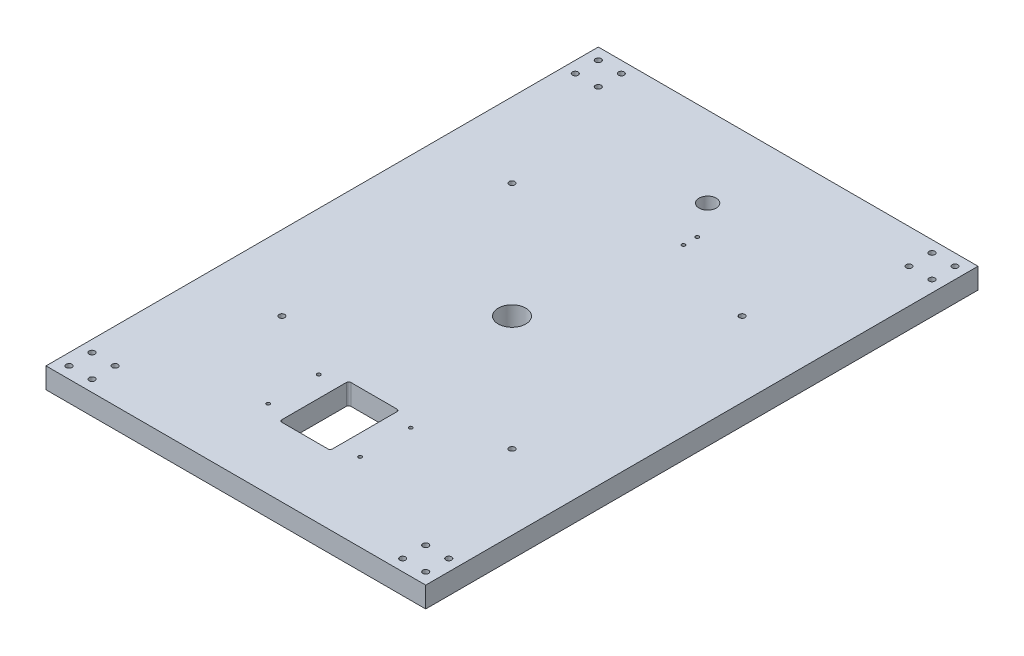
from build123d import *

# Parameters (mm, degrees)
SKETCH1_W           = 330
SKETCH1_H           = 480
SKETCH1_R           = 2.5
SKETCH1_R_2         = 12
SKETCH1_R_3         = 1.5
SKETCH1_R_4         = 7.5
BOSS_EXTRUDE1_DEPTH = 18


with BuildPart() as part:
    # Sketch1 → Boss-Extrude1 (new body)
    with BuildSketch(Plane(origin=(0, 0, 0), x_dir=(1, 0, 0), z_dir=(0, 1, 0))):
        with Locations((165, 240)):
            Rectangle(SKETCH1_W, SKETCH1_H)
        with Locations((10, 10)):
            Circle(SKETCH1_R, mode=Mode.SUBTRACT)
        with Locations((30, 10)):
            Circle(SKETCH1_R, mode=Mode.SUBTRACT)
        with Locations((10, 30)):
            Circle(SKETCH1_R, mode=Mode.SUBTRACT)
        with Locations((30, 30)):
            Circle(SKETCH1_R, mode=Mode.SUBTRACT)
        with Locations((320, 30)):
            Circle(SKETCH1_R, mode=Mode.SUBTRACT)
        with Locations((320, 10)):
            Circle(SKETCH1_R, mode=Mode.SUBTRACT)
        with Locations((300, 10)):
            Circle(SKETCH1_R, mode=Mode.SUBTRACT)
        with Locations((300, 30)):
            Circle(SKETCH1_R, mode=Mode.SUBTRACT)
        with Locations((300, 470)):
            Circle(SKETCH1_R, mode=Mode.SUBTRACT)
        with Locations((320, 470)):
            Circle(SKETCH1_R, mode=Mode.SUBTRACT)
        with Locations((320, 450)):
            Circle(SKETCH1_R, mode=Mode.SUBTRACT)
        with Locations((300, 450)):
            Circle(SKETCH1_R, mode=Mode.SUBTRACT)
        with Locations((30, 470)):
            Circle(SKETCH1_R, mode=Mode.SUBTRACT)
        with Locations((10, 470)):
            Circle(SKETCH1_R, mode=Mode.SUBTRACT)
        with Locations((10, 450)):
            Circle(SKETCH1_R, mode=Mode.SUBTRACT)
        with Locations((30, 450)):
            Circle(SKETCH1_R, mode=Mode.SUBTRACT)
        with Locations((65, 140)):
            Circle(SKETCH1_R, mode=Mode.SUBTRACT)
        with Locations((65, 340)):
            Circle(SKETCH1_R, mode=Mode.SUBTRACT)
        with Locations((265, 140)):
            Circle(SKETCH1_R, mode=Mode.SUBTRACT)
        with Locations((265, 340)):
            Circle(SKETCH1_R, mode=Mode.SUBTRACT)
        with Locations((165, 240)):
            Circle(SKETCH1_R_2, mode=Mode.SUBTRACT)
        with Locations((125, 112)):
            Circle(SKETCH1_R_3, mode=Mode.SUBTRACT)
        with Locations((125, 68)):
            Circle(SKETCH1_R_3, mode=Mode.SUBTRACT)
        with Locations((205, 112)):
            Circle(SKETCH1_R_3, mode=Mode.SUBTRACT)
        with Locations((205, 68)):
            Circle(SKETCH1_R_3, mode=Mode.SUBTRACT)
        with Locations((186, 368)):
            Circle(SKETCH1_R_3, mode=Mode.SUBTRACT)
        with Locations((186, 380)):
            Circle(SKETCH1_R_3, mode=Mode.SUBTRACT)
        with Locations((165, 410)):
            Circle(SKETCH1_R_4, mode=Mode.SUBTRACT)
        with BuildLine():
            Line((145, 60), (185, 60))
            ThreePointArc((185, 60), (186.414213562, 60.585786438), (187, 62))
            Line((187, 62), (187, 118))
            ThreePointArc((187, 118), (186.414213562, 119.414213562), (185, 120))
            Line((185, 120), (145, 120))
            ThreePointArc((145, 120), (143.585786438, 119.414213562), (143, 118))
            Line((143, 118), (143, 62))
            ThreePointArc((143, 62), (143.585786438, 60.585786438), (145, 60))
        make_face(mode=Mode.SUBTRACT)
    extrude(amount=BOSS_EXTRUDE1_DEPTH)


solid = part.part
